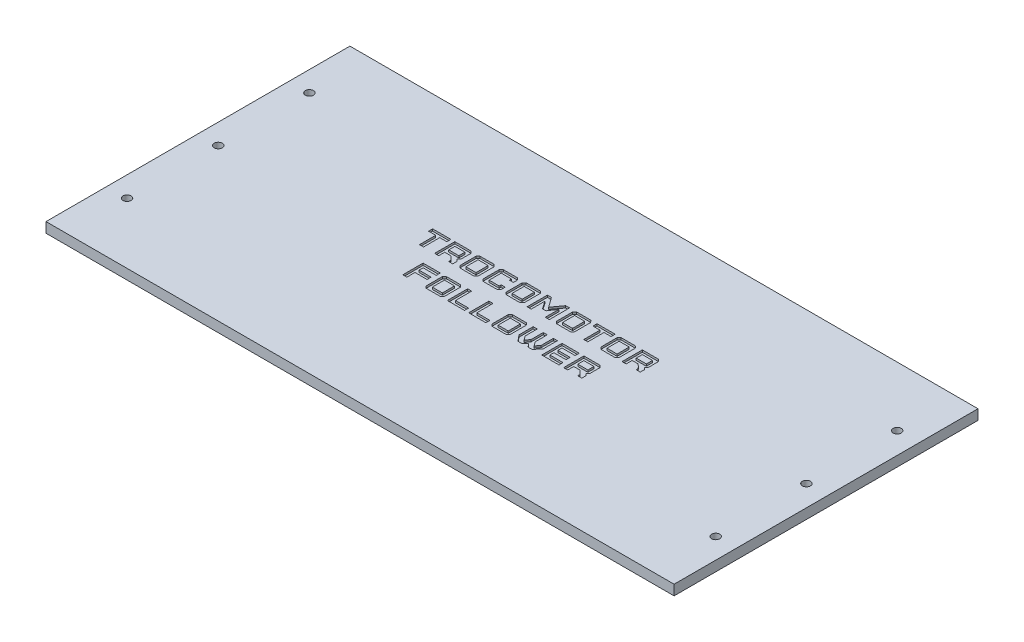
from build123d import *

# Parameters (mm, degrees)
SKETCH1_W           = 310
SKETCH1_H           = 150
BOSS_EXTRUDE1_DEPTH = 5
SKETCH2_W           = 4.98553719
SKETCH2_H           = 3.012396695
SKETCH2_H_2         = 5.995867769
SKETCH2_W_2         = 4.985537191
CUT_EXTRUDE1_DEPTH  = 1
SKETCH3_R           = 2
CUT_EXTRUDE2_DEPTH  = 6


with BuildPart() as part:
    # Sketch1 → Boss-Extrude1 (new body)
    with BuildSketch(Plane(origin=(0, 0, 0), x_dir=(1, 0, 0), z_dir=(0, 1, 0))):
        Rectangle(SKETCH1_W, SKETCH1_H)
    extrude(amount=BOSS_EXTRUDE1_DEPTH)

    # Sketch2 → Cut-Extrude1 (cut)
    with BuildSketch(Plane(origin=(0, 5, 0), x_dir=(1, 0, 0), z_dir=(0, 1, 0))):
        Polygon((-50.972727273, 7.311112148), (-52.966528926, 7.311112148), (-52.966528926, 15.309046033), (-56.468595041, 15.309046033), (-56.468595041, 17.311112148), (-47.499586777, 17.311112148), (-47.499586777, 15.309046033), (-50.972727273, 15.309046033), align=None)
        Polygon((-36.54214876, 7.311112148), (-38.529752066, 7.311112148), (-38.529752066, 8.294583223), (-39.52768595, 9.313178264), (-40.531818182, 10.296649338), (-43.515289256, 10.296649338), (-43.515289256, 7.311112148), (-45.517355372, 7.311112148), (-45.517355372, 17.311112148), (-37.531818182, 17.311112148), (-36.54214876, 16.292517107), (-36.54214876, 11.292517107), (-37.531818182, 10.296649338), (-36.54214876, 9.313178264), align=None)
        with Locations((-41.022520661, 13.802847686)):
            Rectangle(SKETCH2_W, SKETCH2_H, mode=Mode.SUBTRACT)
        Polygon((-26.080578512, 7.311112148), (-33.074380165, 7.311112148), (-34.066115702, 8.294583223), (-34.066115702, 16.292517107), (-33.074380165, 17.311112148), (-26.080578512, 17.311112148), (-25.090909091, 16.292517107), (-25.090909091, 8.294583223), align=None)
        with Locations((-29.571280992, 12.311112149)):
            Rectangle(SKETCH2_W, SKETCH2_H_2, mode=Mode.SUBTRACT)
        Polygon((-14.629338843, 7.311112148), (-21.623140496, 7.311112148), (-22.614876033, 8.294583223), (-22.614876033, 16.292517107), (-21.623140496, 17.311112148), (-14.629338843, 17.311112148), (-13.639669421, 16.292517107), (-13.639669421, 14.313178264), (-15.627272727, 14.313178264), (-15.627272727, 15.309046033), (-20.612809917, 15.309046033), (-20.612809917, 9.313178264), (-15.627272727, 9.313178264), (-15.627272727, 10.296649338), (-13.639669421, 10.296649338), (-13.639669421, 8.294583223), align=None)
        Polygon((-3.310330579, 7.311112148), (-10.304132231, 7.311112148), (-11.295867769, 8.294583223), (-11.295867769, 16.292517107), (-10.304132231, 17.311112148), (-3.310330579, 17.311112148), (-2.320661157, 16.292517107), (-2.320661157, 8.294583223), align=None)
        with Locations((-6.801033058, 12.311112149)):
            Rectangle(SKETCH2_W, SKETCH2_H_2, mode=Mode.SUBTRACT)
        Polygon((2.157438017, 7.311112148), (0.155371901, 7.311112148), (0.155371901, 17.311112148), (2.157438017, 17.311112148), (5.642975207, 12.46400471), (9.186363636, 17.311112148), (11.109917355, 17.311112148), (11.109917355, 7.311112148), (9.109917355, 7.311112148), (9.109917355, 14.054913801), (6.502479339, 10.211938594), (4.82892562, 10.211938594), (2.157438017, 14.054913801), align=None)
        Polygon((21.575619835, 7.311112148), (14.581818182, 7.311112148), (13.590082645, 8.294583223), (13.590082645, 16.292517107), (14.581818182, 17.311112148), (21.575619835, 17.311112148), (22.565289256, 16.292517107), (22.565289256, 8.294583223), align=None)
        with Locations((18.084917355, 12.311112149)):
            Rectangle(SKETCH2_W, SKETCH2_H_2, mode=Mode.SUBTRACT)
        Polygon((30.111570248, 7.311112148), (28.117768595, 7.311112148), (28.117768595, 15.309046033), (24.615702479, 15.309046033), (24.615702479, 17.311112148), (33.584710744, 17.311112148), (33.584710744, 15.309046033), (30.111570248, 15.309046033), align=None)
        Polygon((43.552479339, 7.311112148), (36.558677686, 7.311112148), (35.566942149, 8.294583223), (35.566942149, 16.292517107), (36.558677686, 17.311112148), (43.552479339, 17.311112148), (44.54214876, 16.292517107), (44.54214876, 8.294583223), align=None)
        with Locations((40.06177686, 12.311112149)):
            Rectangle(SKETCH2_W_2, SKETCH2_H_2, mode=Mode.SUBTRACT)
        Polygon((55.99338843, 7.311112148), (54.005785124, 7.311112148), (54.005785124, 8.294583223), (53.00785124, 9.313178264), (52.003719008, 10.296649338), (49.020247934, 10.296649338), (49.020247934, 7.311112148), (47.018181818, 7.311112148), (47.018181818, 17.311112148), (55.003719008, 17.311112148), (55.99338843, 16.292517107), (55.99338843, 11.292517107), (55.003719008, 10.296649338), (55.99338843, 9.313178264), align=None)
        with Locations((51.513016529, 13.802847686)):
            Rectangle(SKETCH2_W, SKETCH2_H, mode=Mode.SUBTRACT)
        Polygon((-42.192975207, -9.688887852), (-44.195041322, -9.688887852), (-44.195041322, 0.311112148), (-35.707438017, 0.311112148), (-35.707438017, -1.690953967), (-42.192975207, -1.690953967), (-42.192975207, -3.705416777), (-36.209504132, -3.705416777), (-36.209504132, -5.707482893), (-42.192975207, -5.707482893), align=None)
        Polygon((-25.683884298, -9.688887852), (-32.67768595, -9.688887852), (-33.669421488, -8.705416777), (-33.669421488, -0.707482893), (-32.67768595, 0.311112148), (-25.683884298, 0.311112148), (-24.694214876, -0.707482893), (-24.694214876, -8.705416777), align=None)
        with Locations((-29.174586777, -4.688887852)):
            Rectangle(SKETCH2_W, SKETCH2_H_2, mode=Mode.SUBTRACT)
        Polygon((-22.218181818, 0.311112148), (-20.216115702, 0.311112148), (-20.216115702, -7.686821736), (-13.730578512, -7.686821736), (-13.730578512, -9.688887852), (-22.218181818, -9.688887852), align=None)
        Polygon((-11.692561983, 0.311112148), (-9.690495868, 0.311112148), (-9.690495868, -7.686821736), (-3.204958678, -7.686821736), (-3.204958678, -9.688887852), (-11.692561983, -9.688887852), align=None)
        Polygon((6.818595041, -9.688887852), (-0.175206612, -9.688887852), (-1.166942149, -8.705416777), (-1.166942149, -0.707482893), (-0.175206612, 0.311112148), (6.818595041, 0.311112148), (7.808264463, -0.707482893), (7.808264463, -8.705416777), align=None)
        with Locations((3.327892562, -4.688887852)):
            Rectangle(SKETCH2_W, SKETCH2_H_2, mode=Mode.SUBTRACT)
        Polygon((17.641735537, -9.688887852), (16.129338843, -7.903763885), (14.643801653, -9.688887852), (12.641735537, -9.688887852), (10.145867769, -6.703350662), (10.145867769, 0.311112148), (12.145867769, 0.311112148), (12.145867769, -5.707482893), (13.660330579, -7.686821736), (15.131404959, -5.707482893), (15.131404959, 0.311112148), (17.125206612, 0.311112148), (17.125206612, -5.707482893), (18.639669421, -7.686821736), (20.123140496, -5.707482893), (20.123140496, 0.311112148), (22.110743802, 0.311112148), (22.110743802, -6.703350662), (19.643801653, -9.688887852), align=None)
        Polygon((32.867768595, -9.688887852), (24.380165289, -9.688887852), (24.380165289, 0.311112148), (32.867768595, 0.311112148), (32.867768595, -1.690953967), (26.382231405, -1.690953967), (26.382231405, -3.705416777), (32.365702479, -3.705416777), (32.365702479, -5.707482893), (26.382231405, -5.707482893), (26.382231405, -7.686821736), (32.867768595, -7.686821736), align=None)
        Polygon((44.145454545, -9.688887852), (42.15785124, -9.688887852), (42.15785124, -8.705416777), (41.159917355, -7.686821736), (40.155785124, -6.703350662), (37.17231405, -6.703350662), (37.17231405, -9.688887852), (35.170247934, -9.688887852), (35.170247934, 0.311112148), (43.155785124, 0.311112148), (44.145454545, -0.707482893), (44.145454545, -5.707482893), (43.155785124, -6.703350662), (44.145454545, -7.686821736), align=None)
        with Locations((39.665082645, -3.197152315)):
            Rectangle(SKETCH2_W, SKETCH2_H, mode=Mode.SUBTRACT)
    extrude(amount=-CUT_EXTRUDE1_DEPTH, mode=Mode.SUBTRACT)

    # Sketch3 → Cut-Extrude2 (cut, through all)
    with BuildSketch(Plane(origin=(0, 5, 0), x_dir=(1, 0, 0), z_dir=(0, 1, 0))):
        with Locations((-145, 45)):
            Circle(SKETCH3_R)
        with Locations((-145, 0)):
            Circle(SKETCH3_R)
        with Locations((-145, -45)):
            Circle(SKETCH3_R)
        with Locations((144.858844931, -44.325661451)):
            Circle(SKETCH3_R)
        with Locations((144.64946667, 0.673851443)):
            Circle(SKETCH3_R)
        with Locations((144.440088408, 45.673364338)):
            Circle(SKETCH3_R)
    extrude(amount=-CUT_EXTRUDE2_DEPTH, mode=Mode.SUBTRACT)


solid = part.part
